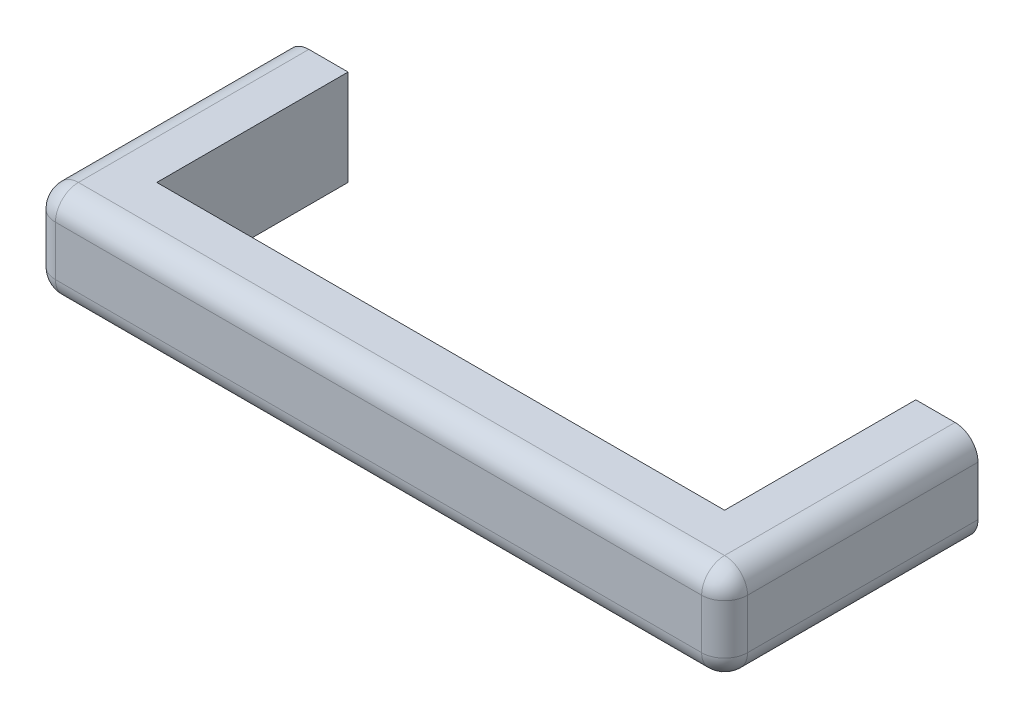
from build123d import *

# Parameters (mm, degrees)
BOSS_EXTRUDE1_DEPTH      = 61.9125
BOSS_EXTRUDE1_DEPTH_BACK = 65.0875
FILLET1_R                = 30.48


with BuildPart() as part:
    # Sketch1 → Boss-Extrude1 (new body, two sides)
    with BuildSketch(Plane(origin=(0, 0, 0), x_dir=(1, 0, 0), z_dir=(0, 1, 0))) as boss_extrude1_sk:
        Polygon((376.9999953, 0), (-376.9999953, 0), (-376.9999953, 254), (-459.5499953, 254), (-459.5499953, -82.55), (459.5499953, -82.55), (459.5499953, 254), (376.9999953, 254), align=None)
    extrude(amount=BOSS_EXTRUDE1_DEPTH)
    extrude(boss_extrude1_sk.sketch, amount=-BOSS_EXTRUDE1_DEPTH_BACK)

    # Fillet1
    fillet1_edges = [part.edges().sort_by_distance(p)[0] for p in [
        (459.5499953, -1.5875, 82.55),
        (-459.5499953, -1.5875, 82.55),
        (-459.5499953, -65.0875, -85.725),
        (-459.5499953, 61.9125, -85.725),
        (0, -65.0875, 82.55),
        (0, 61.9125, 82.55),
        (459.5499953, 61.9125, -85.725),
        (459.5499953, -65.0875, -85.725),
    ]]
    fillet(fillet1_edges, radius=FILLET1_R)


solid = part.part
